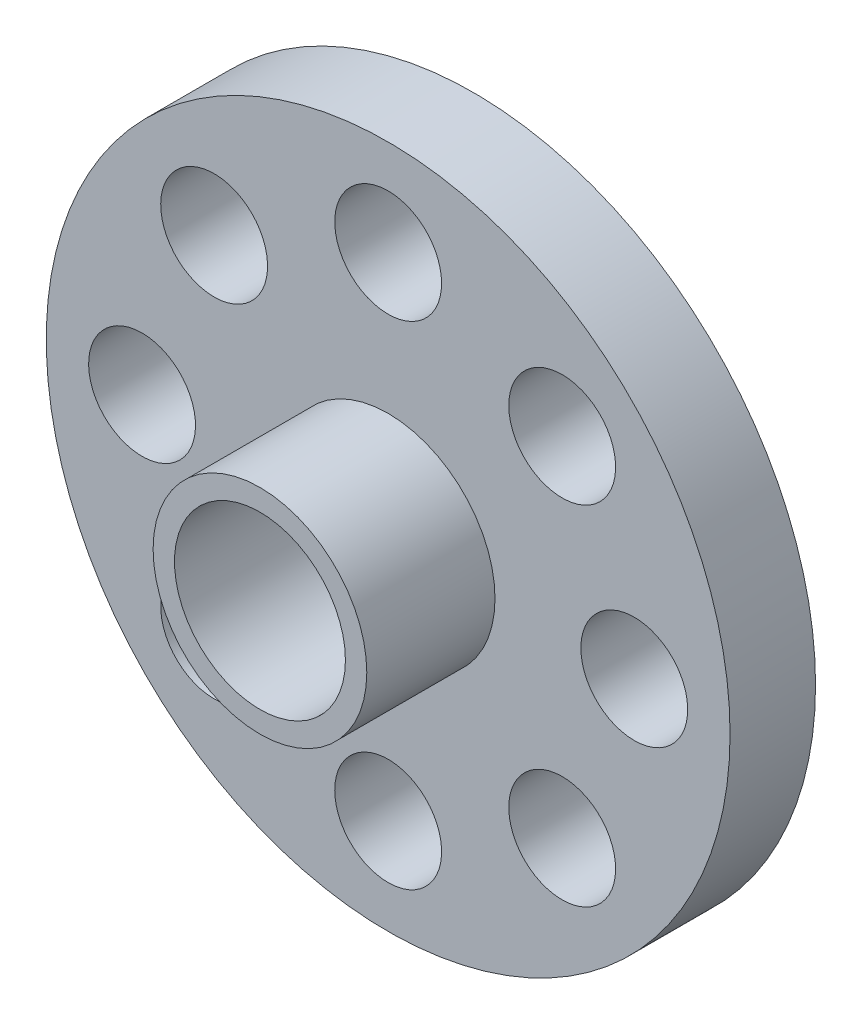
from build123d import *

# Parameters (mm, degrees)
SKETCH_1_R               = 16
SKETCH_1_R_2             = 4
EXTRUDE_2_DEPTH          = 10
SKETCH_3_R               = 16
SKETCH_3_R_2             = 5
CUT_EXTRUDE_2_DEPTH      = 6
SKETCH_4_R               = 2.5
CUT_EXTRUDE_3_DEPTH      = 5
PATTERN_CIRCULAR_1_COUNT = 8


with BuildPart() as part:
    # 草图1 → 凸台-拉伸2 (new body)
    with BuildSketch(Plane.XY):
        Circle(SKETCH_1_R)
        Circle(SKETCH_1_R_2, mode=Mode.SUBTRACT)
    extrude(amount=EXTRUDE_2_DEPTH)

    # 草图3 → 切除-拉伸2 (cut)
    with BuildSketch(Plane.XY.offset(10)):
        Circle(SKETCH_3_R)
        Circle(SKETCH_3_R_2, mode=Mode.SUBTRACT)
    extrude(amount=-CUT_EXTRUDE_2_DEPTH, mode=Mode.SUBTRACT)

    # 草图4 → 切除-拉伸3 (cut, through all)
    with BuildSketch(Plane.XY.offset(4)):
        with Locations((0, 11.516849164)):
            Circle(SKETCH_4_R)
    cut_extrude_3 = extrude(amount=-CUT_EXTRUDE_3_DEPTH, mode=Mode.SUBTRACT)

    # 阵列(圆周)1: 切除-拉伸3 ×8 about axis
    pattern_circular_1_axis = Axis((0, 0, 0), (0, 0, 1))
    for i in range(1, PATTERN_CIRCULAR_1_COUNT):
        add(cut_extrude_3.rotate(pattern_circular_1_axis, i * 360 / PATTERN_CIRCULAR_1_COUNT), mode=Mode.SUBTRACT)


solid = part.part
